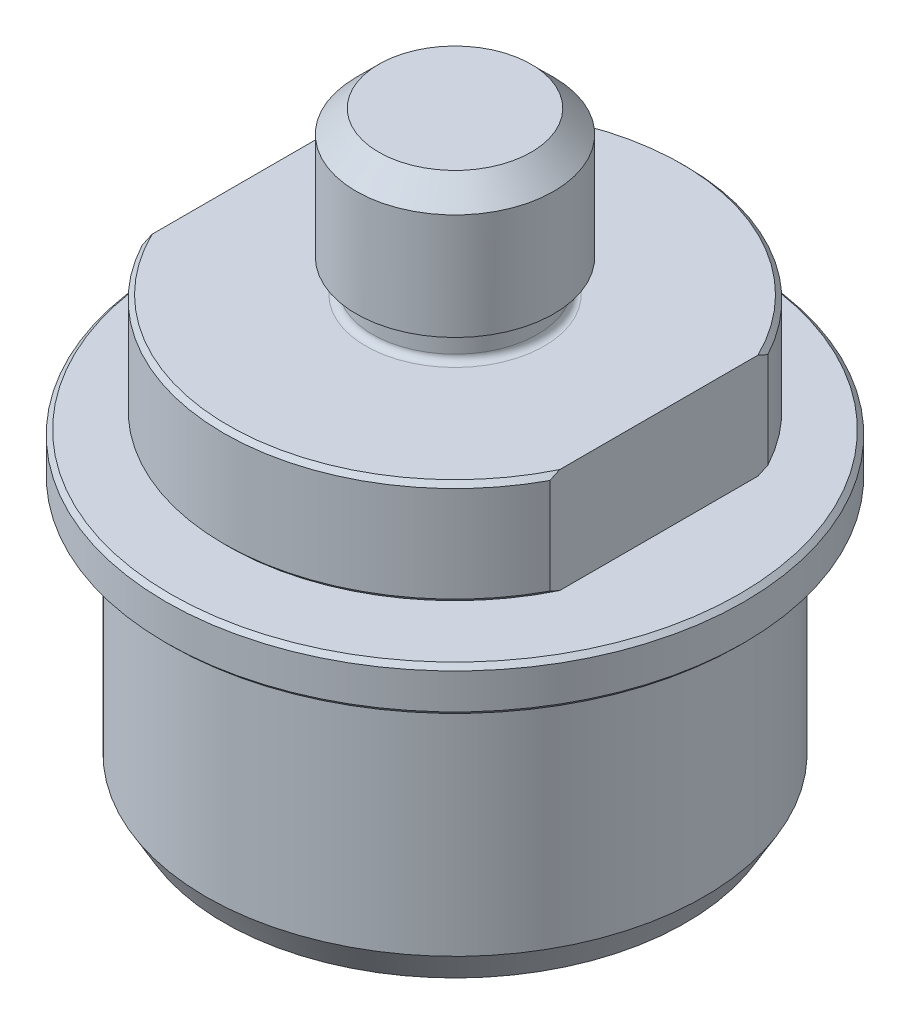
from build123d import *

# Parameters (mm, degrees)
CHAMFER1_SIZE      = 0.508
CHAMFER2_SIZE      = 2.54
CUT_EXTRUDE1_DEPTH = 51.038
CHAMFER3_SIZE      = 0.508
SKETCH3_R          = 1.2192
REVOLVE3_ANGLE     = 330


with BuildPart() as part:
    # Sketch1 → Revolve1 (revolve)
    with BuildSketch(Plane.XY, mode=Mode.PRIVATE) as revolve1_sk:
        with BuildLine():
            Line((0, 18.161), (0, -30.2006))
            Line((0, -30.2006), (4.699, -30.2006))
            Line((4.699, -30.2006), (12.6238, -38.1254))
            Line((12.6238, -38.1254), (12.6238, -48.514))
            ThreePointArc((12.6238, -48.514), (13.070169265, -49.591630735), (14.1478, -50.038))
            Line((14.1478, -50.038), (17.9705, -50.038))
            Line((17.9705, -50.038), (17.9705, -48.1076))
            ThreePointArc((17.9705, -48.1076), (16.7005, -46.8376), (17.9705, -45.5676))
            Line((17.9705, -45.5676), (17.9705, -11.7856))
            Line((17.9705, -11.7856), (25.9969, -11.7856))
            Line((25.9969, -11.7856), (25.9969, 0))
            Line((25.9969, 0), (10.033, 0))
            ThreePointArc((10.033, 0), (9.494184633, 0.223184633), (9.271, 0.762))
            Line((9.271, 0.762), (9.271, 3.683))
            Line((9.271, 3.683), (11.1125, 3.683))
            Line((11.1125, 3.683), (11.1125, 18.161))
            Line((11.1125, 18.161), (0, 18.161))
        make_face()
    revolve(revolve1_sk.sketch.rotate(Axis((0, 18.161, 0), (0, 1, 0)), 90), axis=Axis((0, 18.161, 0), (0, 1, 0)))  # turned: the seam where the file's is

    # Chamfer1
    chamfer1_edges = [part.edges().sort_by_distance(p)[0] for p in [
        (0, -11.7856, 25.9969),
        (0, 0, 25.9969),
    ]]
    chamfer(chamfer1_edges, length=CHAMFER1_SIZE)

    # Chamfer2
    chamfer2_edges = [part.edges().sort_by_distance(p)[0] for p in [
        (0, 18.161, 11.1125),
    ]]
    chamfer(chamfer2_edges, length=CHAMFER2_SIZE)

    # Sketch4 → Cut-Extrude1 (cut, through all)
    with BuildSketch(Plane(origin=(0, 0, 0), x_dir=(1, 0, 0), z_dir=(0, 1, 0))):
        with BuildLine():
            Line((-22.9235, 12.261808894), (-22.9235, -12.261808894))
            ThreePointArc((-22.9235, -12.261808894), (-25.9969, 0), (-22.9235, 12.261808894))
        make_face()
        with BuildLine():
            Line((22.9235, 12.261808894), (22.9235, -12.261808894))
            ThreePointArc((22.9235, -12.261808894), (25.9969, 0), (22.9235, 12.261808894))
        make_face()
    extrude(amount=-CUT_EXTRUDE1_DEPTH, mode=Mode.SUBTRACT)


with BuildPart() as body_2:
    # Sketch2 → Revolve2 (revolve)
    with BuildSketch(Plane.XY, mode=Mode.PRIVATE) as revolve2_sk:
        with BuildLine():
            Line((18.0213, -13.1572), (18.0213, -40.8178))
            Line((18.0213, -40.8178), (19.939, -40.8178))
            ThreePointArc((19.939, -40.8178), (20.65742049, -41.11537951), (20.955, -41.8338))
            Line((20.955, -41.8338), (20.955, -48.2092))
            Line((20.955, -48.2092), (25.950442443, -48.2092))
            Line((25.950442443, -48.2092), (28.0035, -44.6532))
            Line((28.0035, -44.6532), (28.0035, -18.923))
            ThreePointArc((28.0035, -18.923), (28.226684633, -18.384184633), (28.7655, -18.161))
            Line((28.7655, -18.161), (32.512, -18.161))
            Line((32.512, -18.161), (32.512, -13.1572))
            Line((32.512, -13.1572), (18.0213, -13.1572))
        make_face()
    revolve(revolve2_sk.sketch.rotate(Axis((0, 0, 0), (0, 1, 0)), 90), axis=Axis((0, 0, 0), (0, 1, 0)))  # turned: the seam where the file's is

    # Chamfer3
    chamfer3_edges = [body_2.edges().sort_by_distance(p)[0] for p in [
        (0, -13.1572, 32.512),
        (0, -18.161, 32.512),
    ]]
    chamfer(chamfer3_edges, length=CHAMFER3_SIZE)


with BuildPart() as body_3:
    # Sketch3 → Revolve3 (revolve)
    with BuildSketch(Plane.XY):
        with Locations((17.9705, -46.8376)):
            Circle(SKETCH3_R)
    revolve(axis=Axis((0, 0, 0), (0, -1, 0)), revolution_arc=REVOLVE3_ANGLE)


solid = Compound([part.part, body_2.part, body_3.part])
